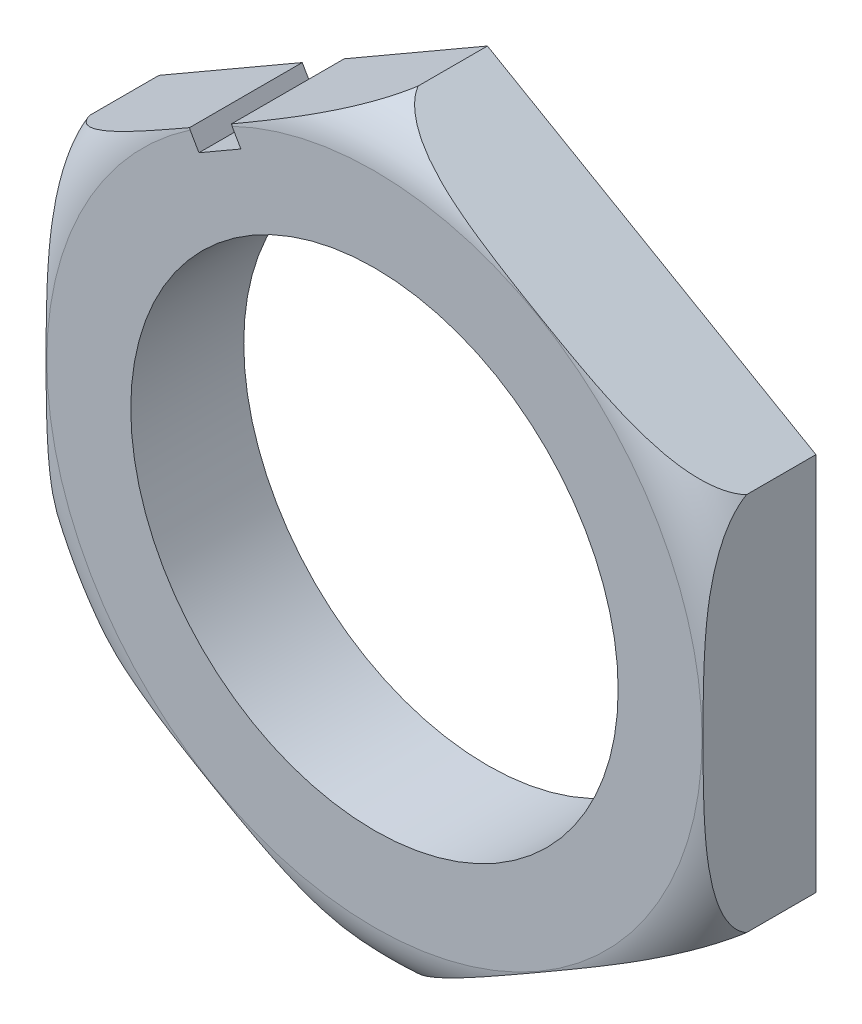
from build123d import *

# Parameters (mm, degrees)
SKETCH_1_R          = 7.55
EXTRUDE_1_DEPTH     = 3.5
CUT_EXTRUDE_1_DEPTH = 27.5


with BuildPart() as part:
    # Эскиз1 → Бобышка-Вытянуть1 (new body)
    with BuildSketch(Plane.XY):
        Polygon((0, 11.75), (-10.175798494, 5.875), (-10.175798494, -5.875), (0, -11.75), (10.175798494, -5.875), (10.175798494, 5.875), align=None)
        Circle(SKETCH_1_R, mode=Mode.SUBTRACT)
    extrude(amount=EXTRUDE_1_DEPTH)

    # Эскиз3 → Вырез-Повернуть2 (revolve, cut)
    with BuildSketch(Plane(origin=(0, 0, 0), x_dir=(0, 0, -1), z_dir=(1, 0, 0))):
        with BuildLine():
            Line((-2.149262527, 11.75), (-3.5, 11.75))
            Line((-3.5, 11.75), (-3.5, 10.15))
            ThreePointArc((-3.5, 10.15), (-3.06988498, 11.157045866), (-2.149262527, 11.75))
        make_face()
    revolve(axis=Axis((0, 0, 10.349500572), (0, 0, -1)), mode=Mode.SUBTRACT)

    # Эскиз4 → Вырез-Вытянуть1 (cut)
    with BuildSketch(Plane.XY.offset(20)):
        Polygon((-4.438380194, 9.1875), (-5.7374183, 8.4375), (-5.4374183, 7.917884758), (-4.138380194, 8.667884758), align=None)
    extrude(amount=-CUT_EXTRUDE_1_DEPTH, mode=Mode.SUBTRACT)


solid = part.part
